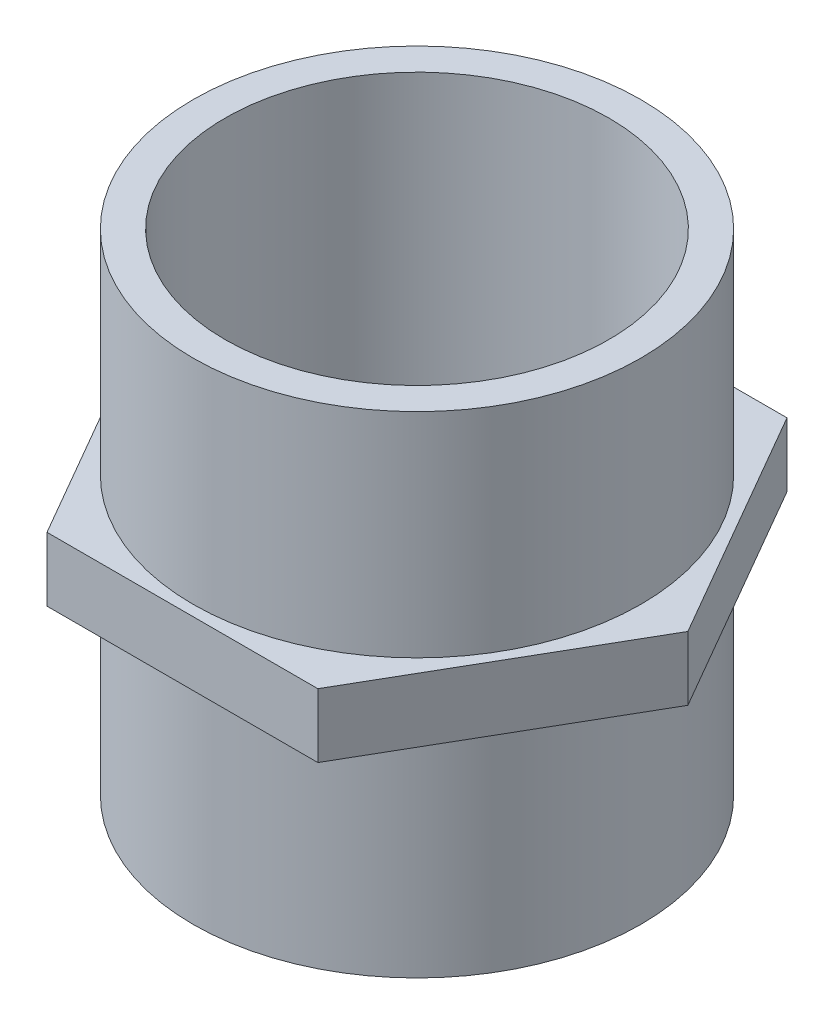
from build123d import *

# Parameters (mm, degrees)
BOSS_EXTRUDE1_DEPTH = 1.5
SKETCH2_R           = 10.5
BOSS_EXTRUDE2_DEPTH = 10
SKETCH3_R           = 9
CUT_EXTRUDE1_DEPTH  = 24


with BuildPart() as part:
    # Sketch1 → Boss-Extrude1 (new body, symmetric)
    with BuildSketch(Plane(origin=(0, 0, 0), x_dir=(1, 0, 0), z_dir=(0, 1, 0))):
        Polygon((6.350852961, -11), (12.701705922, 0), (6.350852961, 11), (-6.350852961, 11), (-12.701705922, 0), (-6.350852961, -11), align=None)
    extrude(amount=BOSS_EXTRUDE1_DEPTH, both=True)

    # Sketch2 → Boss-Extrude2 (add)
    with BuildSketch(Plane(origin=(0, 1.5, 0), x_dir=(1, 0, 0), z_dir=(0, 1, 0))):
        Circle(SKETCH2_R)
    boss_extrude2 = extrude(amount=BOSS_EXTRUDE2_DEPTH)

    # Mirror1: Boss-Extrude2 across plane
    add(boss_extrude2.mirror(Plane.ZX))

    # Sketch3 → Cut-Extrude1 (cut, through all)
    with BuildSketch(Plane(origin=(0, 11.5, 0), x_dir=(1, 0, 0), z_dir=(0, 1, 0))):
        Circle(SKETCH3_R)
    extrude(amount=-CUT_EXTRUDE1_DEPTH, mode=Mode.SUBTRACT)


solid = part.part
